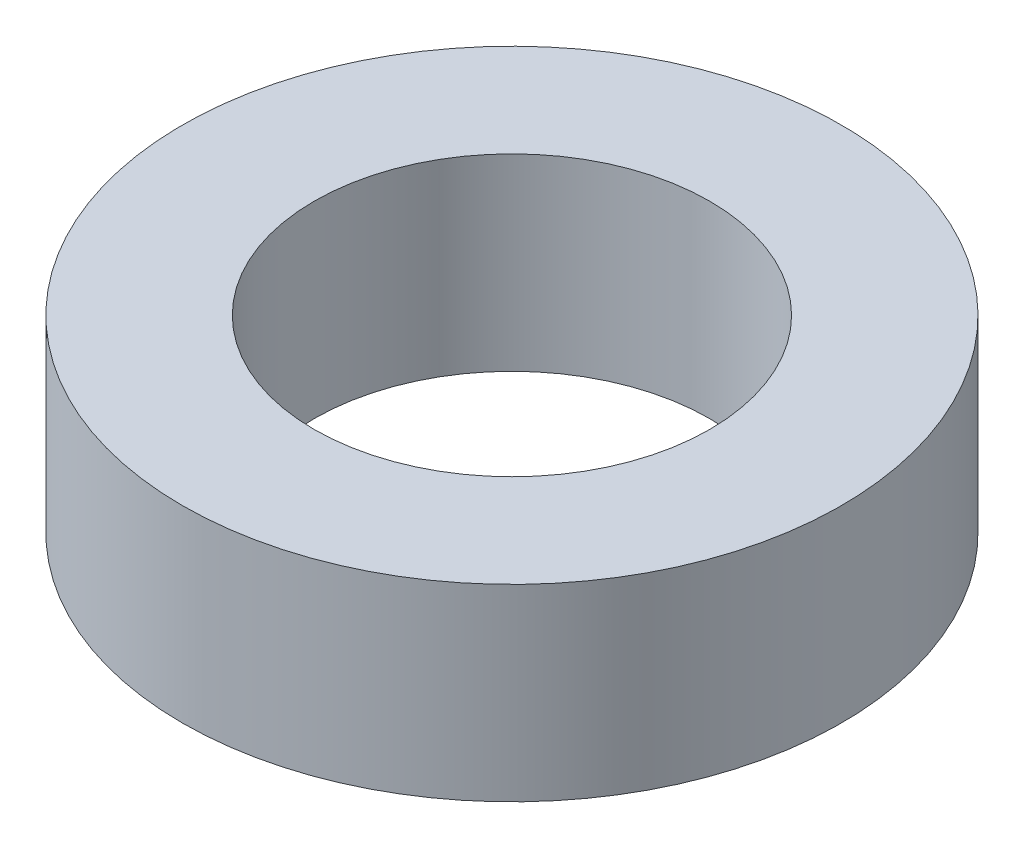
from build123d import *

# Parameters (mm, degrees)
SKETCH3_R           = 3.5
SKETCH3_R_2         = 2.1
BOSS_EXTRUDE1_DEPTH = 2


with BuildPart() as part:
    # Sketch3 → Boss-Extrude1 (new body)
    with BuildSketch(Plane(origin=(0, 0, 0), x_dir=(1, 0, 0), z_dir=(0, 1, 0))):
        Circle(SKETCH3_R)
        Circle(SKETCH3_R_2, mode=Mode.SUBTRACT)
    extrude(amount=BOSS_EXTRUDE1_DEPTH)


solid = part.part
